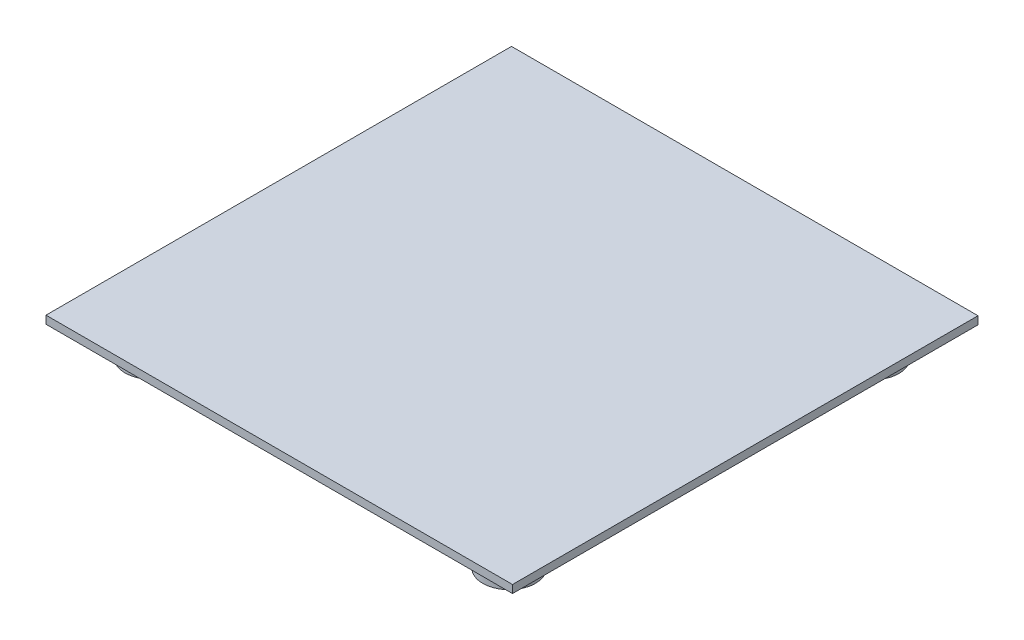
from build123d import *

# Parameters (mm, degrees)
SKETCH2_W           = 176.9
SKETCH2_H           = 176.52
BOSS_EXTRUDE1_DEPTH = 3
SKETCH6_R           = 10
BOSS_EXTRUDE4_DEPTH = 11


with BuildPart() as part:
    # Sketch2 → Boss-Extrude1 (new body)
    with BuildSketch(Plane(origin=(0, 0, 0), x_dir=(1, 0, 0), z_dir=(0, 1, 0))):
        with Locations((88.45, -88.26)):
            Rectangle(SKETCH2_W, SKETCH2_H)
    extrude(amount=BOSS_EXTRUDE1_DEPTH)

    # Sketch6 → Boss-Extrude4 (add)
    with BuildSketch(Plane.XZ):
        with Locations((20, 156.52)):
            Circle(SKETCH6_R)
        with Locations((156.9, 20)):
            Circle(SKETCH6_R)
        with Locations((20, 20)):
            Circle(SKETCH6_R)
        with Locations((156.9, 157.806439708)):
            Circle(SKETCH6_R)
    extrude(amount=BOSS_EXTRUDE4_DEPTH)


solid = part.part
